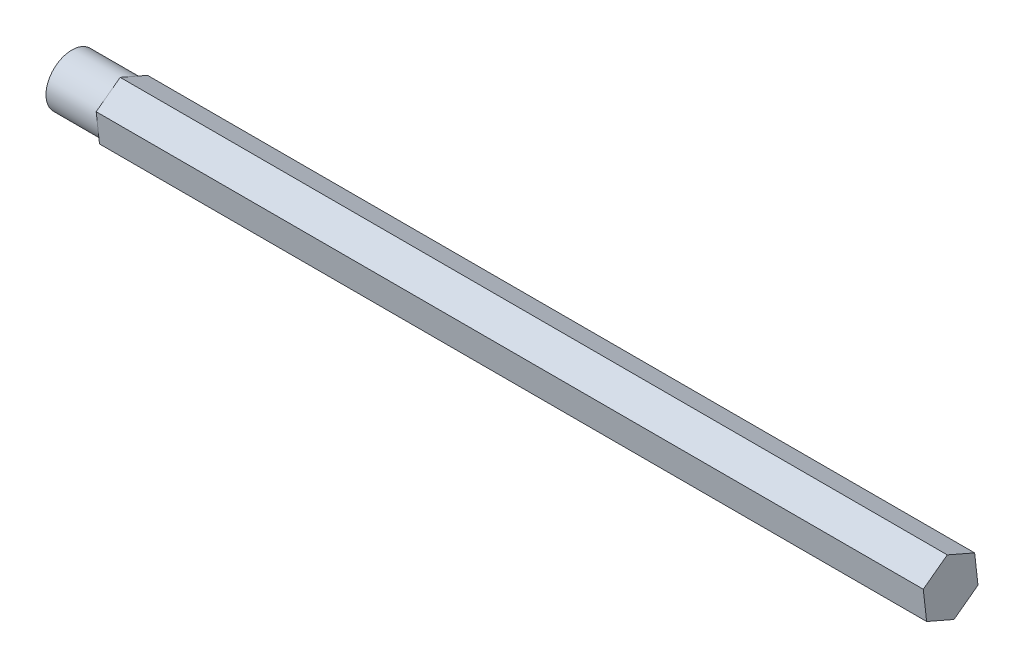
from build123d import *

# Parameters (mm, degrees)
BOSS_EXTRUDE1_DEPTH = 203.2
SKETCH2_R           = 6.35
BOSS_EXTRUDE2_DEPTH = 12.7


with BuildPart() as part:
    # Sketch1 → Boss-Extrude1 (new body)
    with BuildSketch(Plane(origin=(0, 0, 0), x_dir=(0, 0, -1), z_dir=(1, 0, 0))):
        Polygon((6.72189532, -2.929070951), (5.897597513, 4.356796634), (-0.824297807, 7.285867584), (-6.72189532, 2.929070951), (-5.897597513, -4.356796634), (0.824297807, -7.285867584), align=None)
    extrude(amount=BOSS_EXTRUDE1_DEPTH)

    # Sketch2 → Boss-Extrude2 (add)
    with BuildSketch(Plane.ZY):
        Circle(SKETCH2_R)
    extrude(amount=BOSS_EXTRUDE2_DEPTH)


solid = part.part
